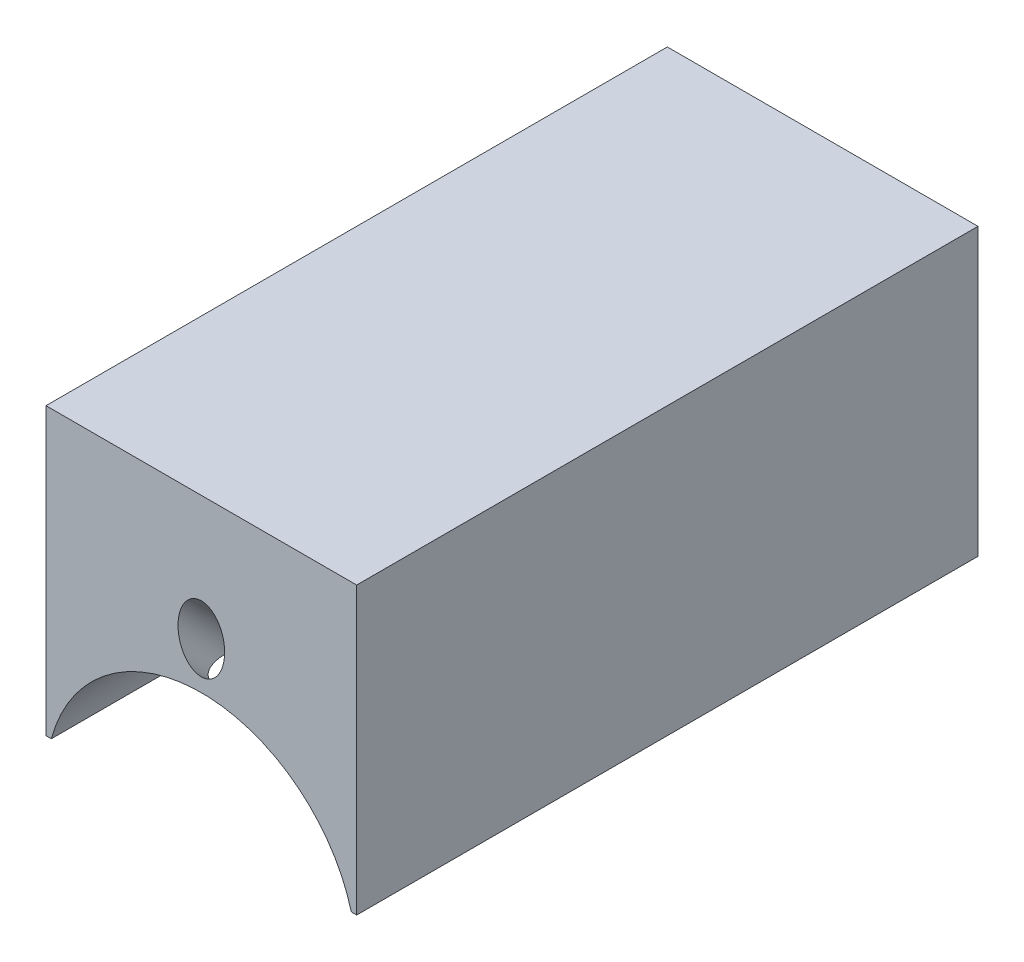
from build123d import *

# Parameters (mm, degrees)
BOSS_EXTRUDE1_DEPTH     = 40
CUT_EXTRUDE4_DEPTH      = 38.253149736
CUT_EXTRUDE4_DEPTH_BACK = 38.253149736
SKETCH6_R               = 1.5
CUT_EXTRUDE5_DEPTH      = 45.579827261
CUT_EXTRUDE5_DEPTH_BACK = 45.579827261
SKETCH9_R               = 1.5
CUT_EXTRUDE8_DEPTH      = 10
CUT_EXTRUDE8_DEPTH_BACK = 2.5
SKETCH16_R              = 1.5


with BuildPart() as part:
    # Sketch2 → Boss-Extrude1 (new body)
    with BuildSketch(Plane.XY):
        with BuildLine():
            Line((10, 12.44732577), (-10, 12.44732577))
            Line((-10, 12.44732577), (-10, -5.95267423))
            Line((-10, -5.95267423), (-9.656086164, -5.95267423))
            ThreePointArc((-9.656086164, -5.95267423), (0, 1.44732577), (9.656086164, -5.95267423))
            Line((9.656086164, -5.95267423), (10, -5.95267423))
            Line((10, -5.95267423), (10, 12.44732577))
        make_face()
    extrude(amount=BOSS_EXTRUDE1_DEPTH)

    # Sketch6 → Cut-Extrude4 (cut, two sides: drawn at the far end of the back side and taken through both)
    with BuildSketch(Plane(origin=(0, 22.223662885, 22.223662885), x_dir=(0, -0.707106781186549, 0.7071067811865461), z_dir=(0, 0.7071067811865461, 0.707106781186549)).offset(-CUT_EXTRUDE4_DEPTH_BACK)):
        with Locations((25.139537037, 0)):
            Circle(SKETCH6_R)
    extrude(amount=CUT_EXTRUDE4_DEPTH + CUT_EXTRUDE4_DEPTH_BACK, mode=Mode.SUBTRACT)

    # Sketch9 → Cut-Extrude5 (cut, two sides: drawn at the far end of the back side and taken through both)
    with BuildSketch(Plane(origin=(0, 2.223662885, -2.223662885), x_dir=(0, 0.7071067811865389, 0.7071067811865562), z_dir=(0, 0.7071067811865562, -0.7071067811865389)).offset(-CUT_EXTRUDE5_DEPTH_BACK)):
        with Locations((3.14473421, 0)):
            Circle(SKETCH9_R)
    extrude(amount=CUT_EXTRUDE5_DEPTH + CUT_EXTRUDE5_DEPTH_BACK, mode=Mode.SUBTRACT)

    # Sketch16 → Cut-Extrude8 (cut, two sides: drawn at the far end of the back side and taken through both)
    with BuildSketch(Plane.XZ.offset(-1.44732577).offset(-CUT_EXTRUDE8_DEPTH_BACK)):
        with Locations((0, 20)):
            Circle(SKETCH16_R)
    extrude(amount=CUT_EXTRUDE8_DEPTH + CUT_EXTRUDE8_DEPTH_BACK, mode=Mode.SUBTRACT)


solid = part.part
